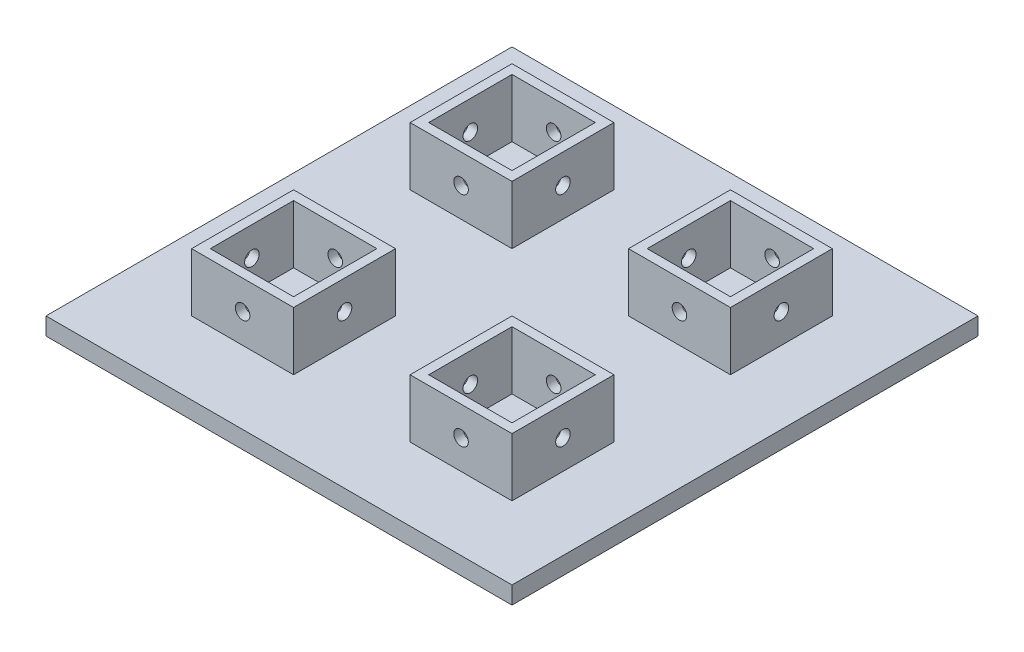
from build123d import *

# Parameters (mm, degrees)
SKETCH1_W                   = 80
SKETCH1_H                   = 80
BOSS_EXTRUDE1_DEPTH         = 3
SKETCH2_W                   = 17.5
SKETCH2_H                   = 17.5
BOSS_EXTRUDE2_DEPTH         = 10
SKETCH3_W                   = 14.3
SKETCH3_H                   = 14.3
CUT_EXTRUDE1_DEPTH          = 10
TAP_DRILL_FOR_M3X0_5_TAP1_D = 2.5
TAP_DRILL_FOR_M3X0_5_TAP2_D = 2.5
MIRROR2_COPY_1_SKETCH_W     = 17.5
MIRROR2_COPY_1_SKETCH_H     = 17.5
MIRROR2_COPY_1_DEPTH        = 10
MIRROR2_COPY_2_SKETCH_W     = 14.3
MIRROR2_COPY_2_SKETCH_H     = 14.3
MIRROR2_COPY_2_DEPTH        = 10
MIRROR2_COPY_3_D            = 2.5
MIRROR2_COPY_4_D            = 2.5


with BuildPart() as part:
    # Sketch1 → Boss-Extrude1 (new body)
    with BuildSketch(Plane(origin=(0, 0, 0), x_dir=(1, 0, 0), z_dir=(0, 1, 0))):
        Rectangle(SKETCH1_W, SKETCH1_H)
    extrude(amount=BOSS_EXTRUDE1_DEPTH)

    # Sketch2 → Boss-Extrude2 (add)
    with BuildSketch(Plane(origin=(0, 3, 0), x_dir=(1, 0, 0), z_dir=(0, 1, 0))):
        with Locations((-18.75, 18.75)):
            Rectangle(SKETCH2_W, SKETCH2_H)
    boss_extrude2 = extrude(amount=BOSS_EXTRUDE2_DEPTH)

    # Sketch3 → Cut-Extrude1 (cut)
    with BuildSketch(Plane(origin=(0, 13, 0), x_dir=(1, 0, 0), z_dir=(0, 1, 0))):
        with Locations((-18.75, 18.75)):
            Rectangle(SKETCH3_W, SKETCH3_H)
    cut_extrude1 = extrude(amount=-CUT_EXTRUDE1_DEPTH, mode=Mode.SUBTRACT)

    # Tap Drill for M3x0.5 Tap1 (through all)
    with Locations(Plane.XY.offset(-10)):
        with Locations((-18.75, 8)):
            tap_drill_for_m3x0_5_tap1 = Hole(TAP_DRILL_FOR_M3X0_5_TAP1_D / 2)

    # Tap Drill for M3x0.5 Tap2 (through all)
    with Locations(Plane.ZY.offset(27.5)):
        with Locations((-18.75, 8)):
            tap_drill_for_m3x0_5_tap2 = Hole(TAP_DRILL_FOR_M3X0_5_TAP2_D / 2)

    # Mirror1: Boss-Extrude2, Cut-Extrude1, Tap Drill for M3x0.5 Tap1, Tap Drill for M3x0.5 Tap2 across plane
    add(boss_extrude2.mirror(Plane.ZY))
    add(cut_extrude1.mirror(Plane.ZY), mode=Mode.SUBTRACT)
    add(tap_drill_for_m3x0_5_tap1.mirror(Plane.ZY), mode=Mode.SUBTRACT)
    add(tap_drill_for_m3x0_5_tap2.mirror(Plane.ZY), mode=Mode.SUBTRACT)

    # Mirror2: Boss-Extrude2, Cut-Extrude1, Tap Drill for M3x0.5 Tap1, Tap Drill for M3x0.5 Tap2 across plane
    add(boss_extrude2.mirror(Plane.XY))
    add(cut_extrude1.mirror(Plane.XY), mode=Mode.SUBTRACT)
    add(tap_drill_for_m3x0_5_tap1.mirror(Plane.XY), mode=Mode.SUBTRACT)
    add(tap_drill_for_m3x0_5_tap2.mirror(Plane.XY), mode=Mode.SUBTRACT)

    # Mirror2 copy 1 sketch → Mirror2 copy 1 (add)
    with BuildSketch(Plane(origin=(0, 3, 0), x_dir=(-1, 0, 0), z_dir=(0, 1, 0))):
        with Locations((-18.75, 18.75)):
            Rectangle(MIRROR2_COPY_1_SKETCH_W, MIRROR2_COPY_1_SKETCH_H)
    extrude(amount=MIRROR2_COPY_1_DEPTH)

    # Mirror2 copy 2 sketch → Mirror2 copy 2 (cut)
    with BuildSketch(Plane(origin=(0, 13, 0), x_dir=(-1, 0, 0), z_dir=(0, 1, 0))):
        with Locations((-18.75, 18.75)):
            Rectangle(MIRROR2_COPY_2_SKETCH_W, MIRROR2_COPY_2_SKETCH_H)
    extrude(amount=-MIRROR2_COPY_2_DEPTH, mode=Mode.SUBTRACT)

    # Mirror2 copy 3 (through all)
    with Locations(Plane(origin=(0, 0, 10), x_dir=(-1, 0, 0), z_dir=(0, 0, -1))):
        with Locations((-18.75, 8)):
            Hole(MIRROR2_COPY_3_D / 2)

    # Mirror2 copy 4 (through all)
    with Locations(Plane(origin=(27.5, 0, 0), x_dir=(0, 0, -1), z_dir=(1, 0, 0))):
        with Locations((-18.75, 8)):
            Hole(MIRROR2_COPY_4_D / 2)


solid = part.part
